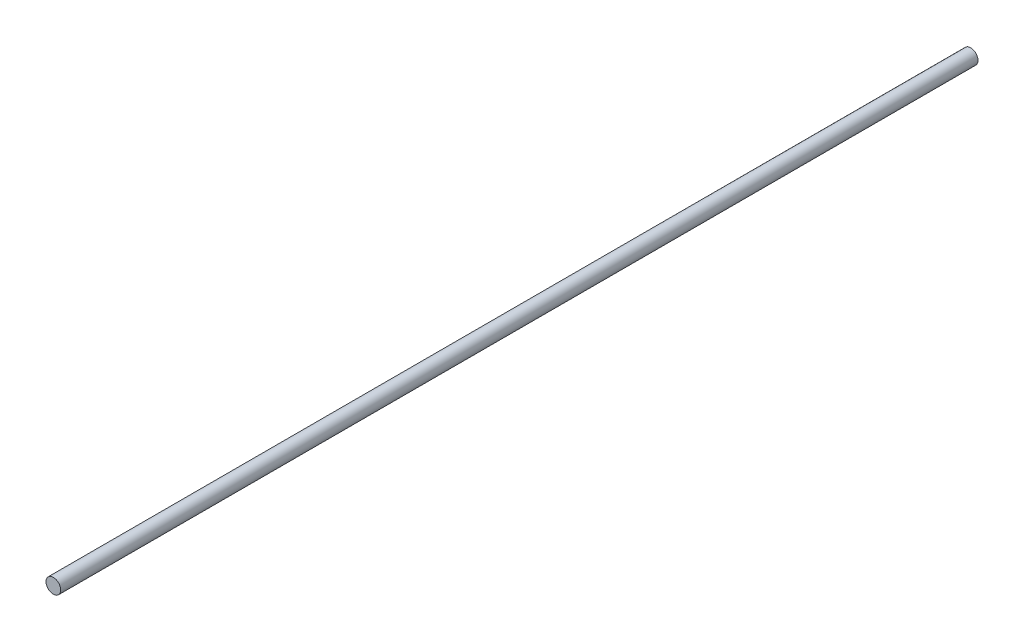
from build123d import *

# Parameters (mm, degrees)
SKETCH1_R           = 2
BOSS_EXTRUDE1_DEPTH = 250


with BuildPart() as part:
    # Sketch1 → Boss-Extrude1 (new body)
    with BuildSketch(Plane.XY):
        Circle(SKETCH1_R)
    extrude(amount=BOSS_EXTRUDE1_DEPTH)


solid = part.part
